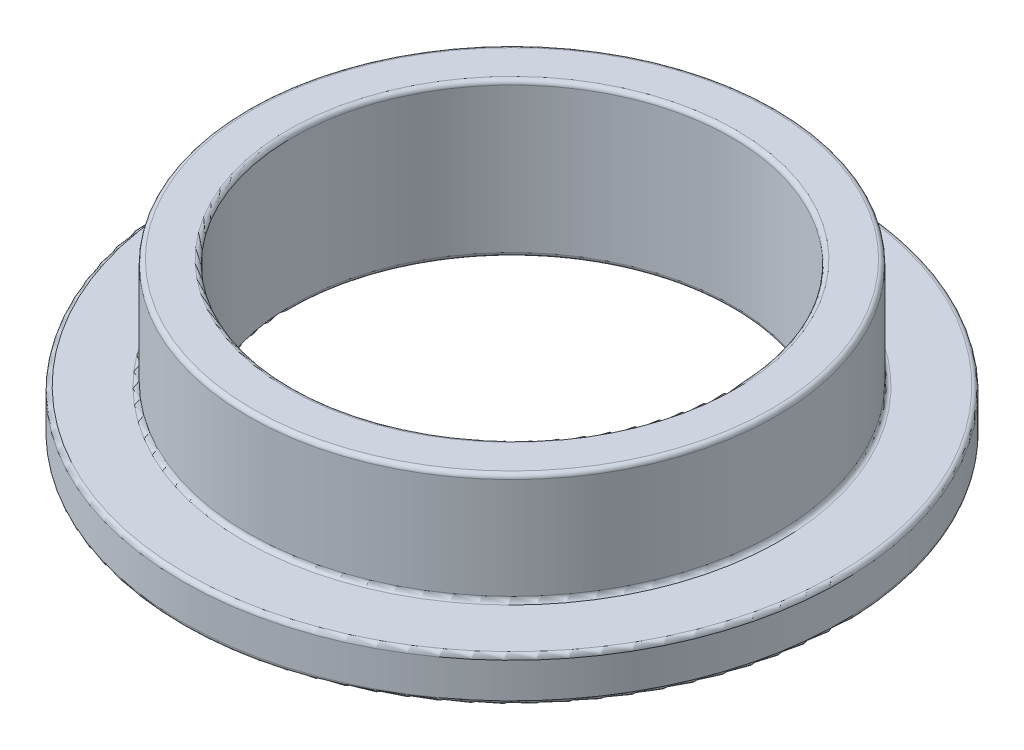
from build123d import *

# Parameters (mm, degrees)
SKETCH3_R           = 6
SKETCH3_R_2         = 5
BOSS_EXTRUDE1_DEPTH = 3.5
SKETCH4_R           = 7.5
SKETCH4_R_2         = 6
BOSS_EXTRUDE2_DEPTH = 1
FILLET1_R           = 0.1


with BuildPart() as part:
    # Sketch3 → Boss-Extrude1 (new body)
    with BuildSketch(Plane(origin=(0, 0, 0), x_dir=(1, 0, 0), z_dir=(0, 1, 0))):
        Circle(SKETCH3_R)
        Circle(SKETCH3_R_2, mode=Mode.SUBTRACT)
    extrude(amount=BOSS_EXTRUDE1_DEPTH)

    # Sketch4 → Boss-Extrude2 (add)
    with BuildSketch(Plane(origin=(0, 0, 0), x_dir=(1, 0, 0), z_dir=(0, 1, 0))):
        Circle(SKETCH4_R)
        Circle(SKETCH4_R_2, mode=Mode.SUBTRACT)
    extrude(amount=BOSS_EXTRUDE2_DEPTH)

    # Fillet1
    fillet1_edges = [part.edges().sort_by_distance(p)[0] for p in [
        (-7.5, 0, 0),
        (-6, 1, 0),
        (-6, 3.5, 0),
        (-5, 0, 0),
        (-5, 3.5, 0),
        (-7.5, 1, 0),
    ]]
    fillet(fillet1_edges, radius=FILLET1_R)


solid = part.part
